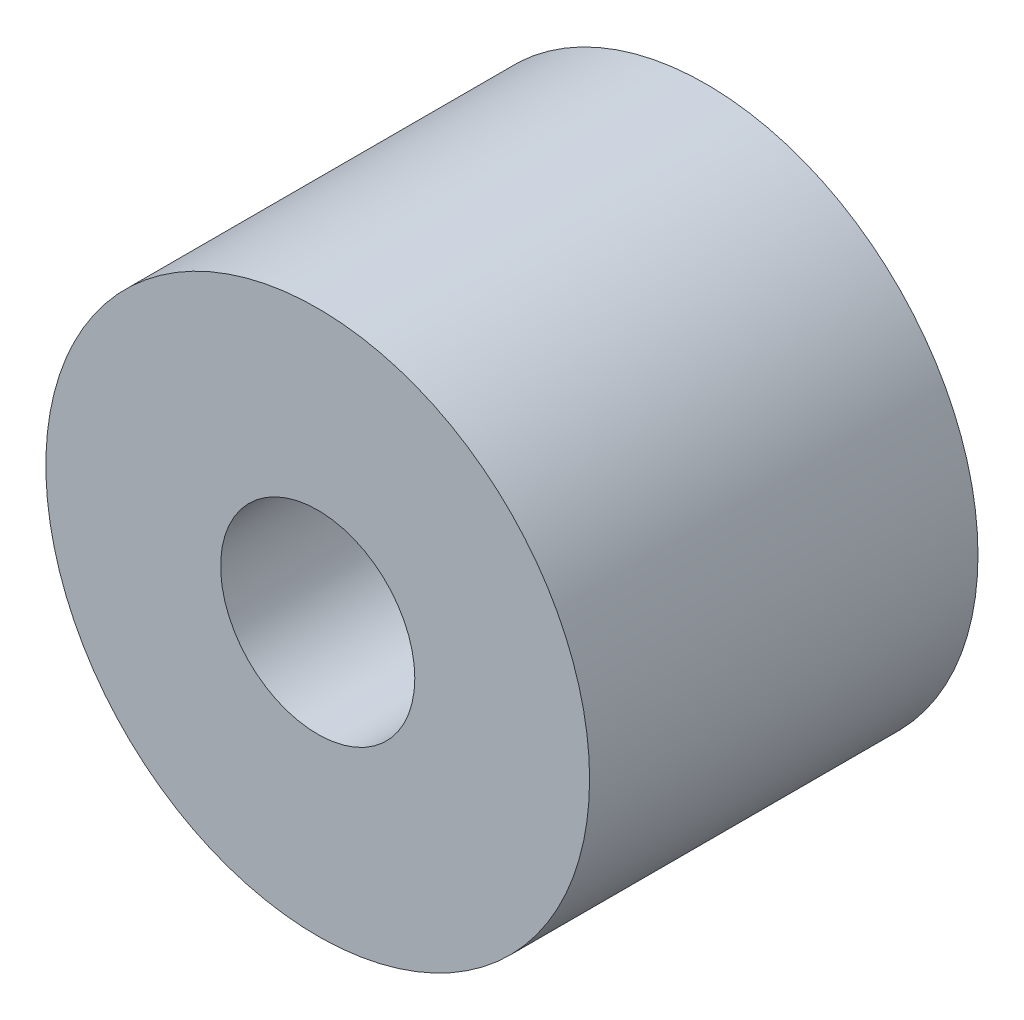
from build123d import *

# Parameters (mm, degrees)
SKETCH1_R           = 3.5
SKETCH1_R_2         = 1.25
BOSS_EXTRUDE1_DEPTH = 5


with BuildPart() as part:
    # Sketch1 → Boss-Extrude1 (new body)
    with BuildSketch(Plane.XY):
        Circle(SKETCH1_R)
        Circle(SKETCH1_R_2, mode=Mode.SUBTRACT)
    extrude(amount=BOSS_EXTRUDE1_DEPTH)


solid = part.part
